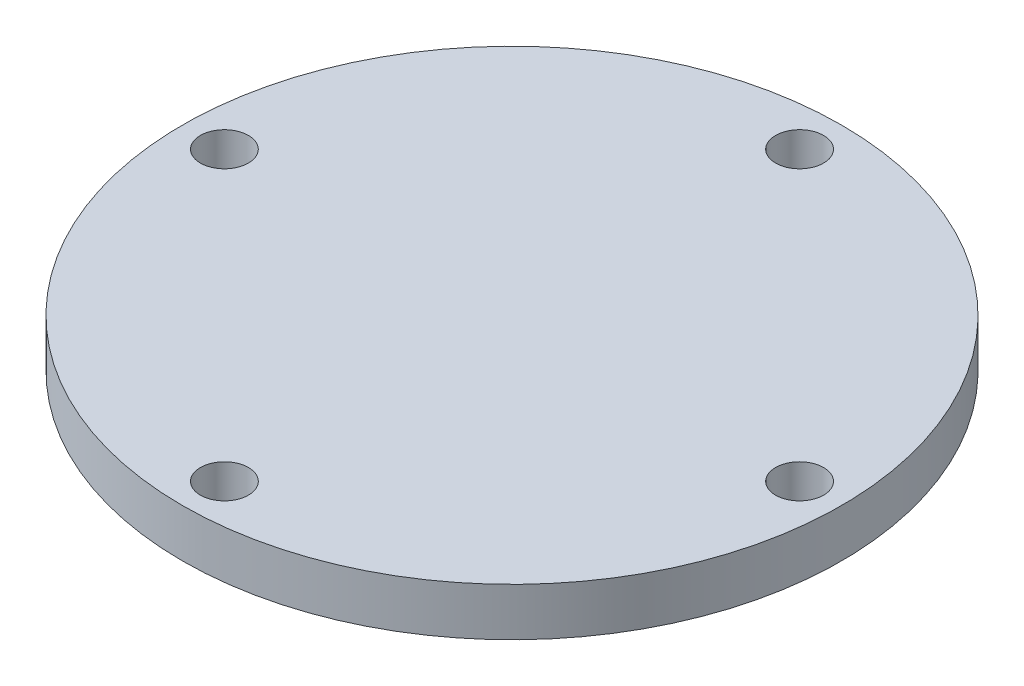
from build123d import *

# Parameters (mm, degrees)
SKETCH2_R           = 27.469
BOSS_EXTRUDE1_DEPTH = 4
SKETCH3_R           = 2
CUT_EXTRUDE1_DEPTH  = 5


with BuildPart() as part:
    # Sketch2 → Boss-Extrude1 (new body)
    with BuildSketch(Plane(origin=(0, 0, 0), x_dir=(1, 0, 0), z_dir=(0, 1, 0))):
        Circle(SKETCH2_R)
    extrude(amount=BOSS_EXTRUDE1_DEPTH)

    # Sketch3 → Cut-Extrude1 (cut, through all)
    with BuildSketch(Plane(origin=(0, 4, 0), x_dir=(1, 0, 0), z_dir=(0, 1, 0))):
        with Locations((-23.971, 0)):
            Circle(SKETCH3_R)
        with Locations((0, 23.971)):
            Circle(SKETCH3_R)
        with Locations((23.971, 0)):
            Circle(SKETCH3_R)
        with Locations((0, -23.971)):
            Circle(SKETCH3_R)
    extrude(amount=-CUT_EXTRUDE1_DEPTH, mode=Mode.SUBTRACT)


solid = part.part
